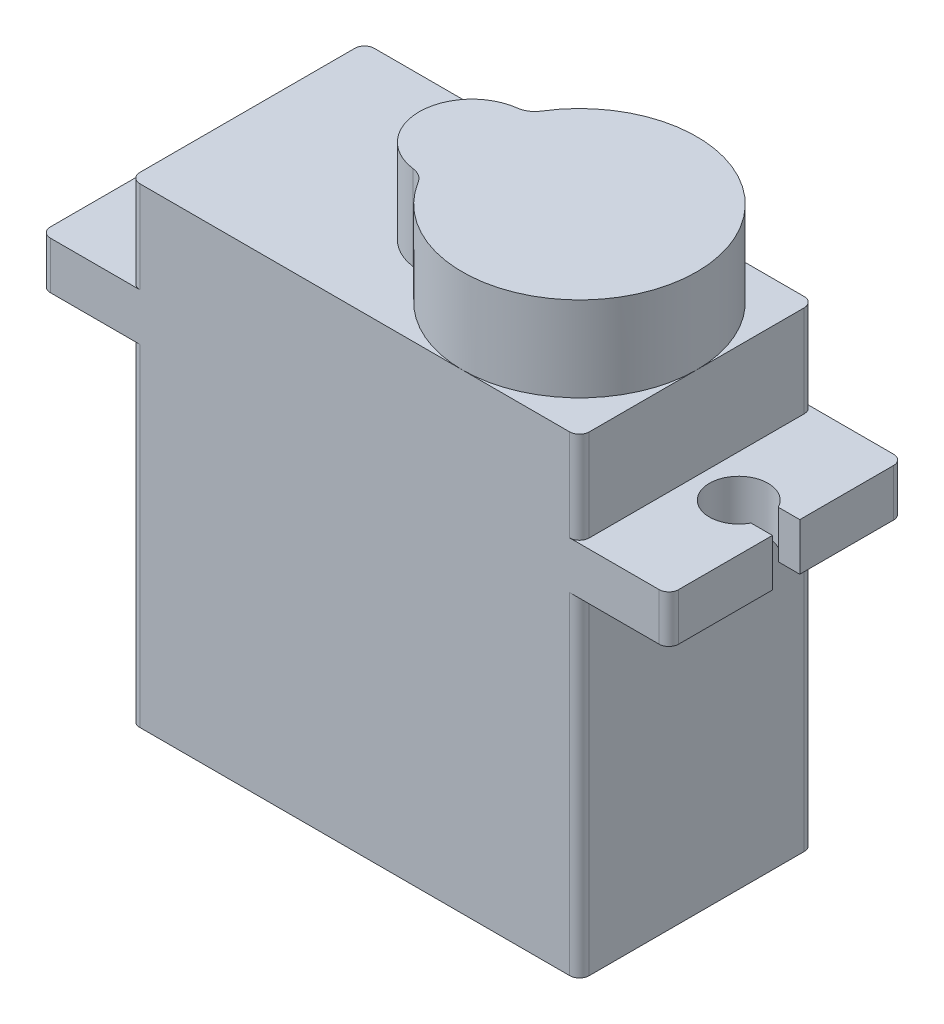
from build123d import *

# Parameters (mm, degrees)
SKETCH1_W           = 23
SKETCH1_H           = 12
BOSS_EXTRUDE1_DEPTH = 24.1
SKETCH2_R           = 6
SKETCH2_R_2         = 2.7
BOSS_EXTRUDE2_DEPTH = 4.34
BOSS_EXTRUDE4_START = 16.98
SKETCH4_W           = 4.575
SKETCH4_H           = 12
BOSS_EXTRUDE4_DEPTH = 2.42
SKETCH5_R           = 1.5
CUT_EXTRUDE1_DEPTH  = 2.42
FILLET1_R           = 1
FILLET2_R           = 0.5


with BuildPart() as part:
    # Sketch1 → Boss-Extrude1 (new body)
    with BuildSketch(Plane(origin=(0, 0, 0), x_dir=(1, 0, 0), z_dir=(0, 1, 0))):
        Rectangle(SKETCH1_W, SKETCH1_H)
    extrude(amount=BOSS_EXTRUDE1_DEPTH)

    # Sketch2 → Boss-Extrude2 (add)
    with BuildSketch(Plane(origin=(0, 24.1, 0), x_dir=(1, 0, 0), z_dir=(0, 1, 0))):
        with Locations((5.5, 0)):
            Circle(SKETCH2_R)
        Circle(SKETCH2_R_2)
    extrude(amount=BOSS_EXTRUDE2_DEPTH)

    # Sketch4 → Boss-Extrude4 (add)
    with BuildSketch(Plane(origin=(0, 0, 0), x_dir=(1, 0, 0), z_dir=(0, 1, 0)).offset(BOSS_EXTRUDE4_START)):
        with Locations((13.7875, 0)):
            Rectangle(SKETCH4_W, SKETCH4_H)
    boss_extrude4 = extrude(amount=BOSS_EXTRUDE4_DEPTH)

    # Sketch5 → Cut-Extrude1 (cut)
    with BuildSketch(Plane(origin=(0, 19.4, 0), x_dir=(1, 0, 0), z_dir=(0, 1, 0))):
        with Locations((13.65, 0)):
            Circle(SKETCH5_R)
        with BuildLine():
            Line((16.075, 0.7), (14.976649916, 0.7))
            ThreePointArc((14.976649916, 0.7), (15.106017664, 0.360572549), (15.15, 0))
            ThreePointArc((15.15, 0), (15.106017664, -0.360572549), (14.976649916, -0.7))
            Line((14.976649916, -0.7), (16.075, -0.7))
            Line((16.075, -0.7), (16.075, 0.7))
        make_face()
    cut_extrude1 = extrude(amount=-CUT_EXTRUDE1_DEPTH, mode=Mode.SUBTRACT)

    # Mirror2: Boss-Extrude4, Cut-Extrude1 across plane
    add(boss_extrude4.mirror(Plane(origin=(0, 0, 0), x_dir=(0, 0, 1), z_dir=(1, 0, 0))))
    add(cut_extrude1.mirror(Plane(origin=(0, 0, 0), x_dir=(0, 0, 1), z_dir=(1, 0, 0))), mode=Mode.SUBTRACT)

    # Fillet1
    fillet1_edges = [part.edges().sort_by_distance(p)[0] for p in [
        (0.14, 26.27, -2.696367927),
        (0.14, 26.27, 2.696367927),
    ]]
    fillet(fillet1_edges, radius=FILLET1_R)

    # Fillet2
    fillet2_edges = [part.edges().sort_by_distance(p)[0] for p in [
        (11.5, 8.49, 6),
        (11.5, 8.49, -6),
        (16.075, 18.19, -6),
        (16.075, 18.19, 6),
        (-11.5, 8.49, 6),
        (-11.5, 8.49, -6),
        (-16.075, 18.19, -6),
        (-16.075, 18.19, 6),
        (11.5, 21.75, 6),
        (-11.5, 21.75, 6),
        (-11.5, 21.75, -6),
        (11.5, 21.75, -6),
    ]]
    fillet(fillet2_edges, radius=FILLET2_R)


solid = part.part
